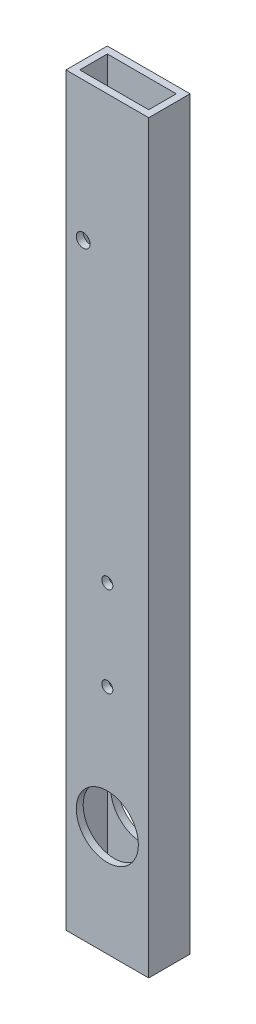
from build123d import *

# Parameters (mm, degrees)
SKETCH1_W           = 38.1
SKETCH1_H           = 19.05
SKETCH1_W_2         = 31.75
SKETCH1_H_2         = 12.7
BOSS_EXTRUDE1_DEPTH = 342.9
SKETCH2_R           = 14.2875
CUT_EXTRUDE1_DEPTH  = 20.05
SKETCH3_R           = 2.54
SKETCH3_R_2         = 3.175
CUT_EXTRUDE2_DEPTH  = 20.05


with BuildPart() as part:
    # Sketch1 → Boss-Extrude1 (new body)
    with BuildSketch(Plane(origin=(0, 0, 0), x_dir=(1, 0, 0), z_dir=(0, 1, 0))):
        with Locations((19.05, 9.525)):
            Rectangle(SKETCH1_W, SKETCH1_H)
        with Locations((19.05, 9.525)):
            Rectangle(SKETCH1_W_2, SKETCH1_H_2, mode=Mode.SUBTRACT)
    extrude(amount=BOSS_EXTRUDE1_DEPTH)

    # Sketch2 → Cut-Extrude1 (cut, through all)
    with BuildSketch(Plane.XY):
        with Locations((19.05, 50.8)):
            Circle(SKETCH2_R)
    extrude(amount=-CUT_EXTRUDE1_DEPTH, mode=Mode.SUBTRACT)

    # Sketch3 → Cut-Extrude2 (cut, through all)
    with BuildSketch(Plane(origin=(0, 0, -19.05), x_dir=(-1, 0, 0), z_dir=(0, 0, -1))):
        with Locations((-19.05, 106.541886393)):
            Circle(SKETCH3_R)
        with Locations((-19.05, 147.996272786)):
            Circle(SKETCH3_R)
        with Locations((-7.946710848, 278.981271676)):
            Circle(SKETCH3_R_2)
    extrude(amount=-CUT_EXTRUDE2_DEPTH, mode=Mode.SUBTRACT)


solid = part.part
